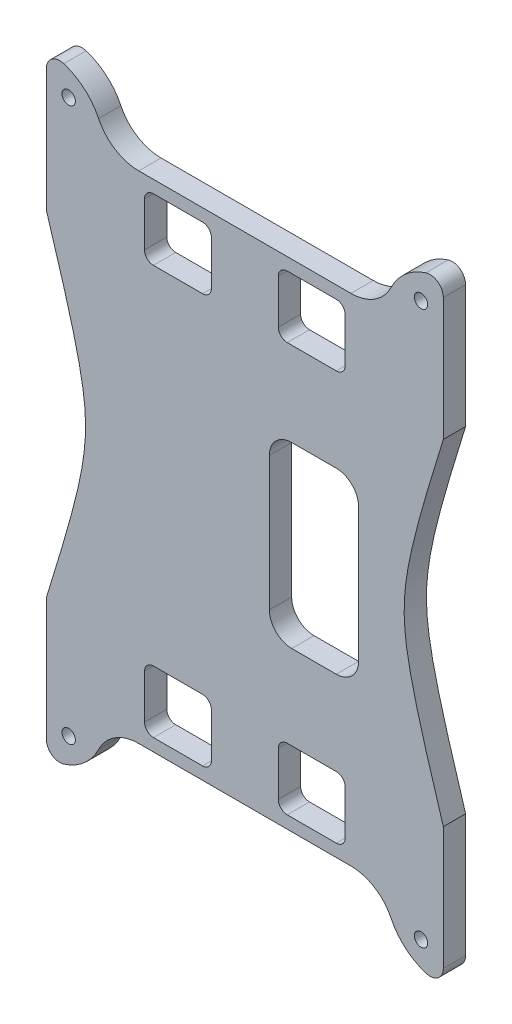
from build123d import *

# Parameters (mm, degrees)
RESSALTO_EXTRUS_O3_DEPTH = 5
ESBO_O4_R                = 1.5
CORTE_EXTRUS_O3_DEPTH    = 10
CORTE_EXTRUS_O4_DEPTH    = 10


with BuildPart() as part:
    # Esboço1 → Ressalto-extrusão3 (new body)
    with BuildSketch(Plane.XY):
        with BuildLine():
            Line((-31.851570772, -17.801096987), (-27.063885949, -17.801096987))
            Line((-27.063885949, -17.801096987), (10.936114051, -17.801096987))
            Line((10.936114051, -17.801096987), (15.723798874, -17.801096987))
            ThreePointArc((15.723798874, -17.801096987), (21.039894205, -19.331201448), (24.729153299, -23.4532709))
            ThreePointArc((24.729153299, -23.4532709), (27.934250919, -27.635644423), (32.536114051, -30.202306605))
            ThreePointArc((32.536114051, -30.202306605), (35.210937986, -29.759166326), (36.436114051, -27.340489001))
            Line((36.436114051, -27.340489001), (36.436114051, -17.801096987))
            Line((36.436114051, -17.801096987), (36.436114051, 0.198903013))
            add(Edge.make_bspline(
                [(36.436114051, 75.398903013), (24.729153299, 37.798903013), (36.436114051, 0.198903013)],
                knots=[0, 0, 0, 1, 1, 1], degree=2, weights=[1, 3, 1]))
            Line((36.436114051, 75.398903013), (36.436114051, 93.398903013))
            Line((36.436114051, 93.398903013), (36.436114051, 102.938295027))
            ThreePointArc((36.436114051, 102.938295027), (35.210937986, 105.356972352), (32.536114051, 105.800112631))
            ThreePointArc((32.536114051, 105.800112631), (27.934250919, 103.23345045), (24.729153299, 99.051076926))
            ThreePointArc((24.729153299, 99.051076926), (21.039894205, 94.929007474), (15.723798874, 93.398903013))
            Line((15.723798874, 93.398903013), (10.936114051, 93.398903013))
            Line((10.936114051, 93.398903013), (-27.063885949, 93.398903013))
            Line((-27.063885949, 93.398903013), (-31.851570772, 93.398903013))
            ThreePointArc((-31.851570772, 93.398903013), (-37.167666102, 94.929007474), (-40.856925197, 99.051076926))
            ThreePointArc((-40.856925197, 99.051076926), (-44.062022817, 103.23345045), (-48.663885949, 105.800112631))
            ThreePointArc((-48.663885949, 105.800112631), (-51.338709884, 105.356972352), (-52.563885949, 102.938295027))
            Line((-52.563885949, 102.938295027), (-52.563885949, 93.398903013))
            Line((-52.563885949, 93.398903013), (-52.563885949, 75.398903013))
            add(Edge.make_bspline(
                [(-52.563885949, 75.398903013), (-40.856925197, 37.798903013), (-52.563885949, 0.198903013)],
                knots=[0, 0, 0, 1, 1, 1], degree=2, weights=[1, 3, 1]))
            Line((-52.563885949, 0.198903013), (-52.563885949, -17.801096987))
            Line((-52.563885949, -17.801096987), (-52.563885949, -27.340489001))
            ThreePointArc((-52.563885949, -27.340489001), (-51.338709884, -29.759166326), (-48.663885949, -30.202306605))
            ThreePointArc((-48.663885949, -30.202306605), (-44.062022817, -27.635644423), (-40.856925197, -23.4532709))
            ThreePointArc((-40.856925197, -23.4532709), (-37.167666102, -19.331201448), (-31.851570772, -17.801096987))
        make_face()
    extrude(amount=RESSALTO_EXTRUS_O3_DEPTH)

    # Esboço4 → Corte-extrusão3 (cut)
    with BuildSketch(Plane(origin=(0, 0, 0), x_dir=(-1, 0, 0), z_dir=(0, 0, -1))):
        with Locations((-31.436114051, 99.800112631)):
            Circle(ESBO_O4_R)
        with Locations((47.563885949, 99.800112631)):
            Circle(ESBO_O4_R)
        with Locations((47.563885949, -24.202306605)):
            Circle(ESBO_O4_R)
        with Locations((-31.436114051, -24.202306605)):
            Circle(ESBO_O4_R)
        with BuildLine():
            Line((-12.436114051, 90.598903013), (-1.436114051, 90.598903013))
            ThreePointArc((-1.436114051, 90.598903013), (-0.021900489, 90.013116575), (0.563885949, 88.598903013))
            Line((0.563885949, 88.598903013), (0.563885949, 78.698903013))
            ThreePointArc((0.563885949, 78.698903013), (-0.021900489, 77.284689451), (-1.436114051, 76.698903013))
            Line((-1.436114051, 76.698903013), (-12.436114051, 76.698903013))
            ThreePointArc((-12.436114051, 76.698903013), (-13.850327613, 77.284689451), (-14.436114051, 78.698903013))
            Line((-14.436114051, 78.698903013), (-14.436114051, 88.598903013))
            ThreePointArc((-14.436114051, 88.598903013), (-13.850327613, 90.013116575), (-12.436114051, 90.598903013))
        make_face()
        with BuildLine():
            Line((17.563885949, 90.598903013), (28.563885949, 90.598903013))
            ThreePointArc((28.563885949, 90.598903013), (29.978099511, 90.013116575), (30.563885949, 88.598903013))
            Line((30.563885949, 88.598903013), (30.563885949, 78.698903013))
            ThreePointArc((30.563885949, 78.698903013), (29.978099511, 77.284689451), (28.563885949, 76.698903013))
            Line((28.563885949, 76.698903013), (17.563885949, 76.698903013))
            ThreePointArc((17.563885949, 76.698903013), (16.149672387, 77.284689451), (15.563885949, 78.698903013))
            Line((15.563885949, 78.698903013), (15.563885949, 88.598903013))
            ThreePointArc((15.563885949, 88.598903013), (16.149672387, 90.013116575), (17.563885949, 90.598903013))
        make_face()
        with BuildLine():
            Line((30.563885949, -13.001096987), (30.563885949, -3.101096987))
            ThreePointArc((30.563885949, -3.101096987), (29.978099511, -1.686883425), (28.563885949, -1.101096987))
            Line((28.563885949, -1.101096987), (17.563885949, -1.101096987))
            ThreePointArc((17.563885949, -1.101096987), (16.149672387, -1.686883425), (15.563885949, -3.101096987))
            Line((15.563885949, -3.101096987), (15.563885949, -13.001096987))
            ThreePointArc((15.563885949, -13.001096987), (16.149672387, -14.415310549), (17.563885949, -15.001096987))
            Line((17.563885949, -15.001096987), (28.563885949, -15.001096987))
            ThreePointArc((28.563885949, -15.001096987), (29.978099511, -14.415310549), (30.563885949, -13.001096987))
        make_face()
        with BuildLine():
            Line((0.563885949, -13.001096987), (0.563885949, -3.101096987))
            ThreePointArc((0.563885949, -3.101096987), (-0.021900489, -1.686883425), (-1.436114051, -1.101096987))
            Line((-1.436114051, -1.101096987), (-12.436114051, -1.101096987))
            ThreePointArc((-12.436114051, -1.101096987), (-13.850327613, -1.686883425), (-14.436114051, -3.101096987))
            Line((-14.436114051, -3.101096987), (-14.436114051, -13.001096987))
            ThreePointArc((-14.436114051, -13.001096987), (-13.850327613, -14.415310549), (-12.436114051, -15.001096987))
            Line((-12.436114051, -15.001096987), (-1.436114051, -15.001096987))
            ThreePointArc((-1.436114051, -15.001096987), (-0.021900489, -14.415310549), (0.563885949, -13.001096987))
        make_face()
    extrude(amount=-CORTE_EXTRUS_O3_DEPTH, mode=Mode.SUBTRACT)

    # Esboço5 → Corte-extrusão4 (cut)
    with BuildSketch(Plane.XY.offset(5)):
        with BuildLine():
            Line((2.436114051, 17.798903013), (12.436114051, 17.798903013))
            ThreePointArc((12.436114051, 17.798903013), (15.971647957, 19.263369107), (17.436114051, 22.798903013))
            Line((17.436114051, 22.798903013), (17.436114051, 52.798903013))
            ThreePointArc((17.436114051, 52.798903013), (15.971647957, 56.334436919), (12.436114051, 57.798903013))
            Line((12.436114051, 57.798903013), (2.436114051, 57.798903013))
            ThreePointArc((2.436114051, 57.798903013), (-1.099419855, 56.334436919), (-2.563885949, 52.798903013))
            Line((-2.563885949, 52.798903013), (-2.563885949, 22.798903013))
            ThreePointArc((-2.563885949, 22.798903013), (-1.099419855, 19.263369107), (2.436114051, 17.798903013))
        make_face()
    extrude(amount=-CORTE_EXTRUS_O4_DEPTH, mode=Mode.SUBTRACT)


solid = part.part
